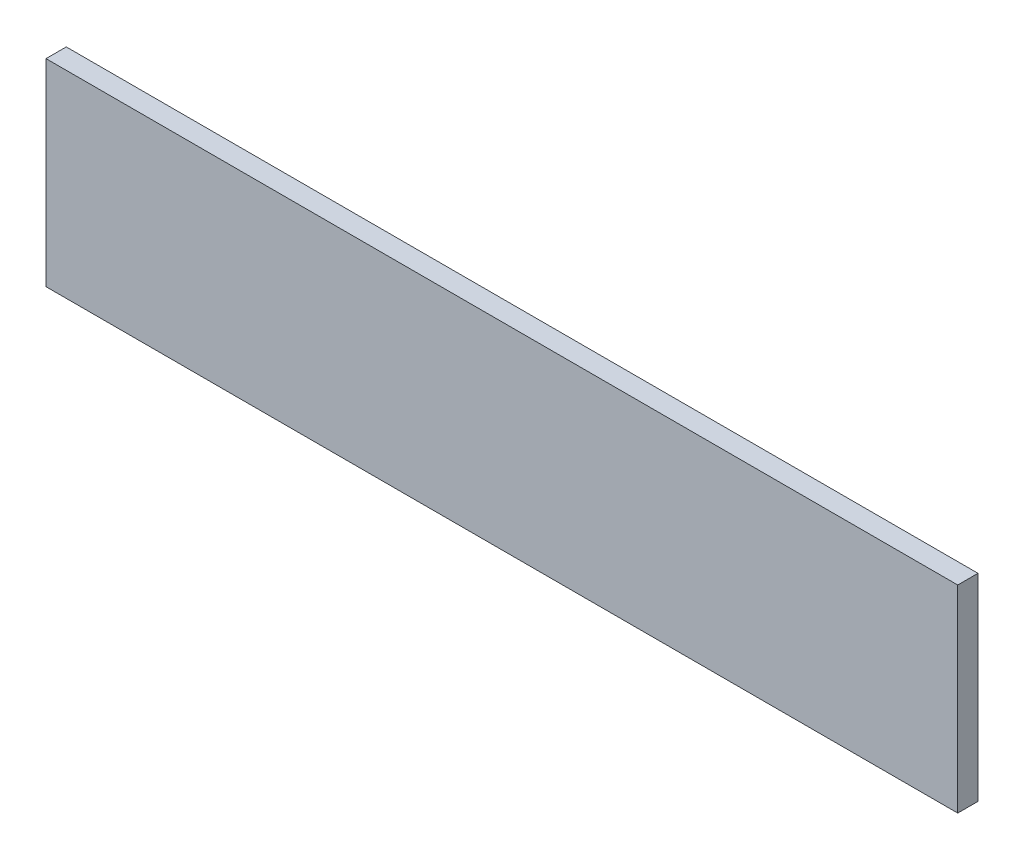
from build123d import *

# Parameters (mm, degrees)
CROQUIS1_W              = 900
CROQUIS1_H              = 195
SALIENTE_EXTRUIR1_DEPTH = 20


with BuildPart() as part:
    # Croquis1 → Saliente-Extruir1 (new body)
    with BuildSketch(Plane.XY):
        with Locations((-66.440831075, 232.766075388)):
            Rectangle(CROQUIS1_W, CROQUIS1_H)
    extrude(amount=SALIENTE_EXTRUIR1_DEPTH)


solid = part.part
